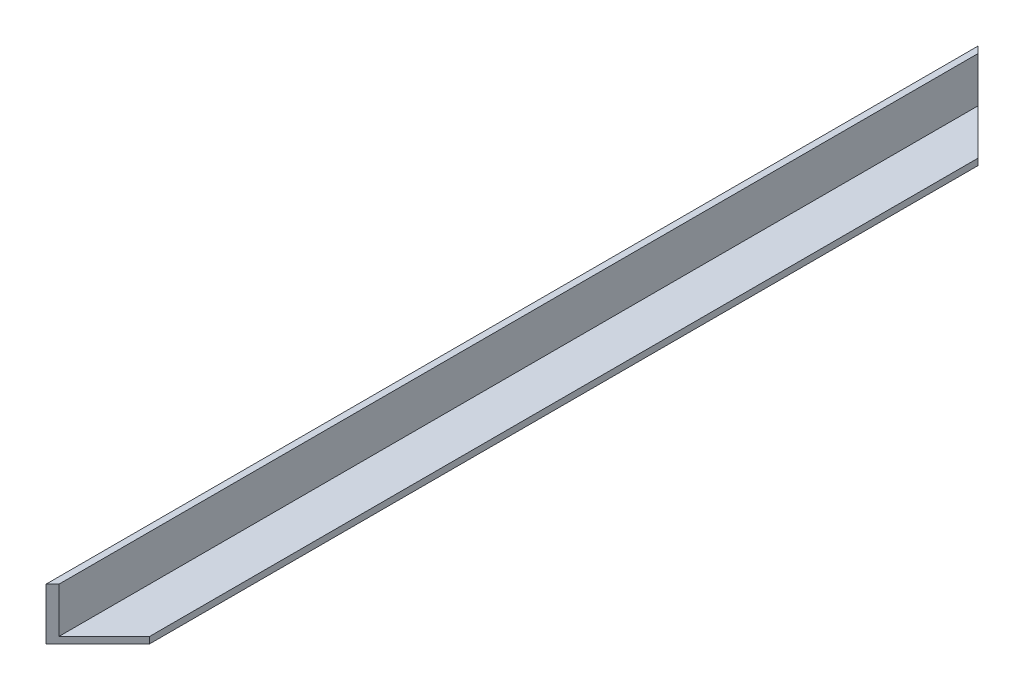
from build123d import *

# Parameters (mm, degrees)
BOSS_EXTRUDE1_DEPTH     = 457.2
CUT_EXTRUDE1_DEPTH      = 23.225
CUT_EXTRUDE1_DEPTH_BACK = 4.175


with BuildPart() as part:
    # Sketch1 → Boss-Extrude1 (new body)
    with BuildSketch(Plane.XY):
        Polygon((0, 0), (25.4, 0), (25.4, 3.175), (3.175, 3.175), (3.175, 25.4), (0, 25.4), align=None)
    extrude(amount=BOSS_EXTRUDE1_DEPTH)

    # Sketch2 → Cut-Extrude1 (cut, two sides)
    with BuildSketch(Plane(origin=(0, 3.175, 0), x_dir=(1, 0, 0), z_dir=(0, 1, 0))) as cut_extrude1_sk:
        Polygon((0, 0), (25.4, -25.4), (25.4, 0), align=None)
        Polygon((0, -457.2), (25.4, -431.8), (25.4, -457.2), align=None)
    extrude(amount=CUT_EXTRUDE1_DEPTH, mode=Mode.SUBTRACT)
    extrude(cut_extrude1_sk.sketch, amount=-CUT_EXTRUDE1_DEPTH_BACK, mode=Mode.SUBTRACT)


solid = part.part
